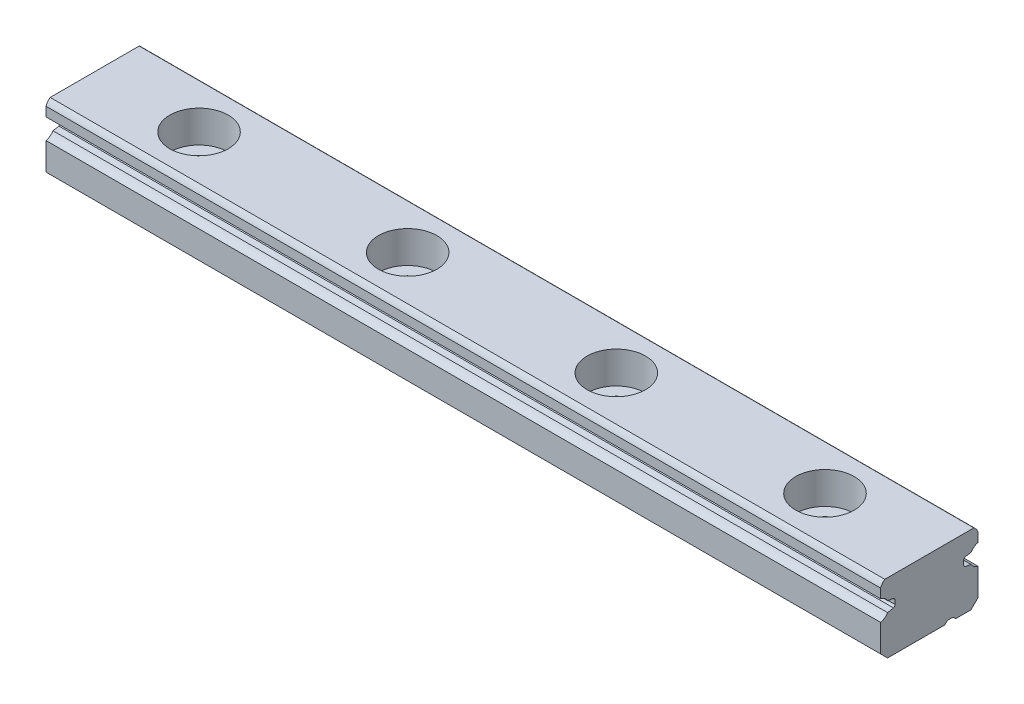
from build123d import *

# Parameters (mm, degrees)
EXTRUDE1_DEPTH  = 60
SKETCH6_R       = 0.5
EXTRUDE2_DEPTH  = 61.309617807
LPATTERN1_COUNT = 3
LPATTERN1_PITCH = 15


with BuildPart() as part:
    # Sketch1 → Extrude1 (new body)
    with BuildSketch(Plane(origin=(0, 0, 0), x_dir=(0, 0, -1), z_dir=(1, 0, 0))):
        with BuildLine():
            Line((-3.5, 0.5), (-3, 0))
            Line((-3, 0), (3, 0))
            Line((3, 0), (3.5, 0.5))
            Line((3.5, 0.5), (3.5, 2.465153077))
            ThreePointArc((3.5, 2.465153077), (3.211148341, 2.591798371), (2.999904622, 2.826))
            Line((2.999904622, 2.826), (2.572, 2.90145113))
            ThreePointArc((2.572, 2.90145113), (2.501845147, 2.968757157), (2.45, 3.051))
            Line((2.45, 3.051), (2.45, 3.349))
            ThreePointArc((2.45, 3.349), (2.501845147, 3.431242843), (2.572, 3.49854887))
            Line((2.572, 3.49854887), (2.999904622, 3.574))
            ThreePointArc((2.999904622, 3.574), (3.211148341, 3.808201629), (3.5, 3.934846923))
            Line((3.5, 3.934846923), (3.5, 4.6))
            ThreePointArc((3.5, 4.6), (3.382052634, 4.824039475), (3.2, 5))
            Line((3.2, 5), (-3.2, 5))
            ThreePointArc((-3.2, 5), (-3.382052634, 4.824039475), (-3.5, 4.6))
            Line((-3.5, 4.6), (-3.5, 3.934846923))
            ThreePointArc((-3.5, 3.934846923), (-3.211148341, 3.808201629), (-2.999904622, 3.574))
            Line((-2.999904622, 3.574), (-2.572, 3.49854887))
            ThreePointArc((-2.572, 3.49854887), (-2.501845147, 3.431242843), (-2.45, 3.349))
            Line((-2.45, 3.349), (-2.45, 3.051))
            ThreePointArc((-2.45, 3.051), (-2.501845147, 2.968757157), (-2.572, 2.90145113))
            Line((-2.572, 2.90145113), (-2.999904622, 2.826))
            ThreePointArc((-2.999904622, 2.826), (-3.211148341, 2.591798371), (-3.5, 2.465153077))
            Line((-3.5, 2.465153077), (-3.5, 0.5))
        make_face()
    extrude(amount=EXTRUDE1_DEPTH)

    # Sketch2 → Cut-Revolve1 (revolve, cut)
    with BuildSketch(Plane(origin=(0, 0, 0), x_dir=(-1, 0, 0), z_dir=(0, 0, -1))):
        Polygon((-7.5, 5), (-5.4, 5), (-5.4, 2.7), (-6.3, 2.7), (-6.3, 0.2), (-6.1, 0), (-7.5, 0), align=None)
    revolve(axis=Axis((7.5, 0, 0), (0, 1, 0)), mode=Mode.SUBTRACT)

    # Sketch3 → Cut-Revolve2 (revolve, cut)
    with BuildSketch(Plane(origin=(45, 0, 0), x_dir=(-1, 0, 0), z_dir=(0, 0, -1))):
        Polygon((-7.5, 5), (-5.4, 5), (-5.4, 2.7), (-6.3, 2.7), (-6.3, 0.2), (-6.1, 0), (-7.5, 0), align=None)
    cut_revolve2 = revolve(axis=Axis((52.5, 0, 0), (0, 1, 0)), mode=Mode.SUBTRACT)

    # Sketch6 → Extrude2 (cut, through all)
    with BuildSketch(Plane(origin=(0, 0, 0), x_dir=(0, 0, -1), z_dir=(1, 0, 0))):
        with Locations((1.5, -0.3)):
            Circle(SKETCH6_R)
    extrude(amount=EXTRUDE2_DEPTH, mode=Mode.SUBTRACT)

    # LPattern1: Cut-Revolve2 ×3
    with Locations(*[(-i * LPATTERN1_PITCH, 0, 0) for i in range(1, LPATTERN1_COUNT)]):
        add(cut_revolve2, mode=Mode.SUBTRACT)


solid = part.part
